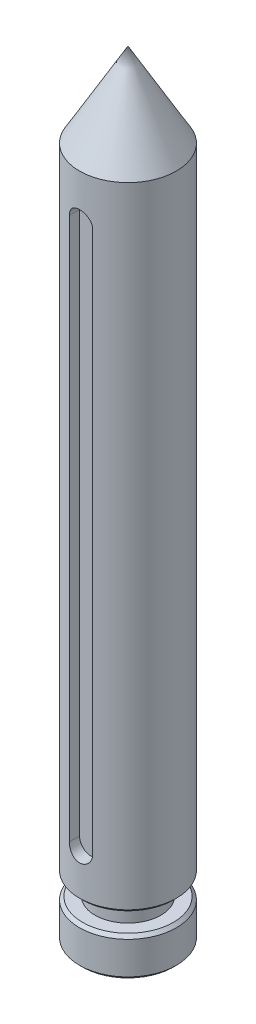
from build123d import *

# Parameters (mm, degrees)
CORTAR_EXTRUIR1_START = 9.5
CORTAR_EXTRUIR1_DEPTH = 7
CHAFL_N1_SIZE         = 0.8


with BuildPart() as part:
    # Croquis2 → Revolución1 (revolve)
    with BuildSketch(Plane.XY):
        Polygon((0, 0), (-12.5, 0), (-12.5, 10), (-8.5, 10), (-8.5, 15), (-12.5, 15), (-12.5, 178.3), (0, 200), align=None)
    revolve(axis=Axis((0, 200, 0), (0, -1, 0)))

    # Croquis3 → Cortar-Extruir1 (cut)
    with BuildSketch(Plane.XY.offset(CORTAR_EXTRUIR1_START)):
        with BuildLine():
            Line((3, 166.7), (3, 26.7))
            ThreePointArc((3, 26.7), (0, 23.7), (-3, 26.7))
            Line((-3, 26.7), (-3, 166.7))
            ThreePointArc((-3, 166.7), (0, 169.7), (3, 166.7))
        make_face()
    extrude(amount=CORTAR_EXTRUIR1_DEPTH, mode=Mode.SUBTRACT)

    # Chaflán1
    chafl_n1_edges = [part.edges().sort_by_distance(p)[0] for p in [
        (12.5, 15, 0),
        (12.5, 10, 0),
        (12.5, 0, 0),
    ]]
    chamfer(chafl_n1_edges, length=CHAFL_N1_SIZE)


solid = part.part
